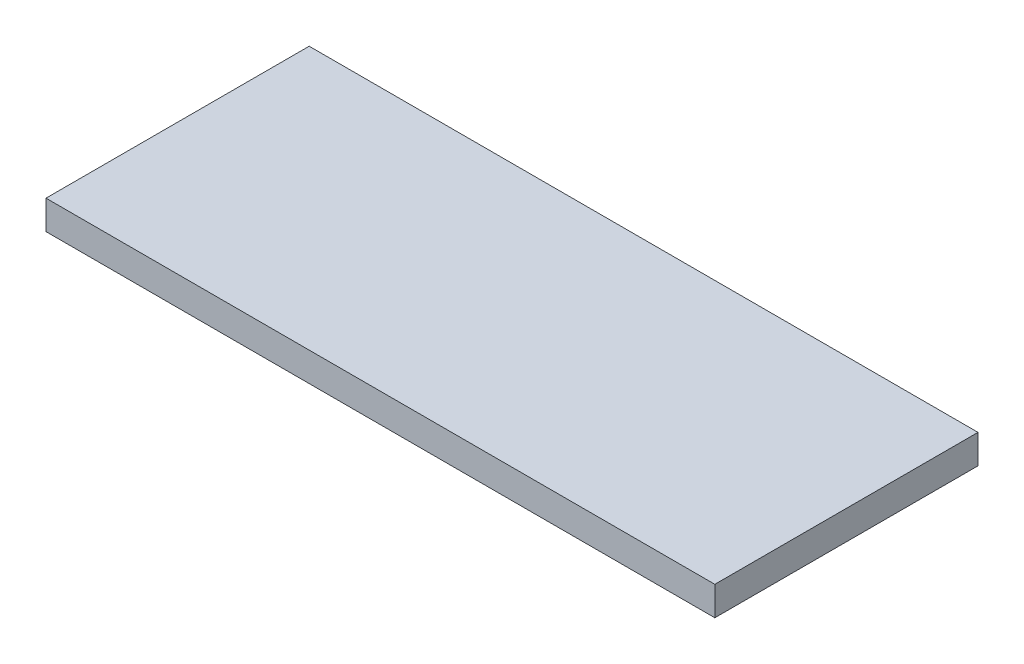
from build123d import *

# Parameters (mm, degrees)
SKETCH1_W           = 415
SKETCH1_H           = 163.3
BOSS_EXTRUDE1_DEPTH = 18


with BuildPart() as part:
    # Sketch1 → Boss-Extrude1 (new body)
    with BuildSketch(Plane(origin=(0, 0, 0), x_dir=(1, 0, 0), z_dir=(0, 1, 0))):
        with Locations((207.5, 81.65)):
            Rectangle(SKETCH1_W, SKETCH1_H)
    extrude(amount=BOSS_EXTRUDE1_DEPTH)


solid = part.part
